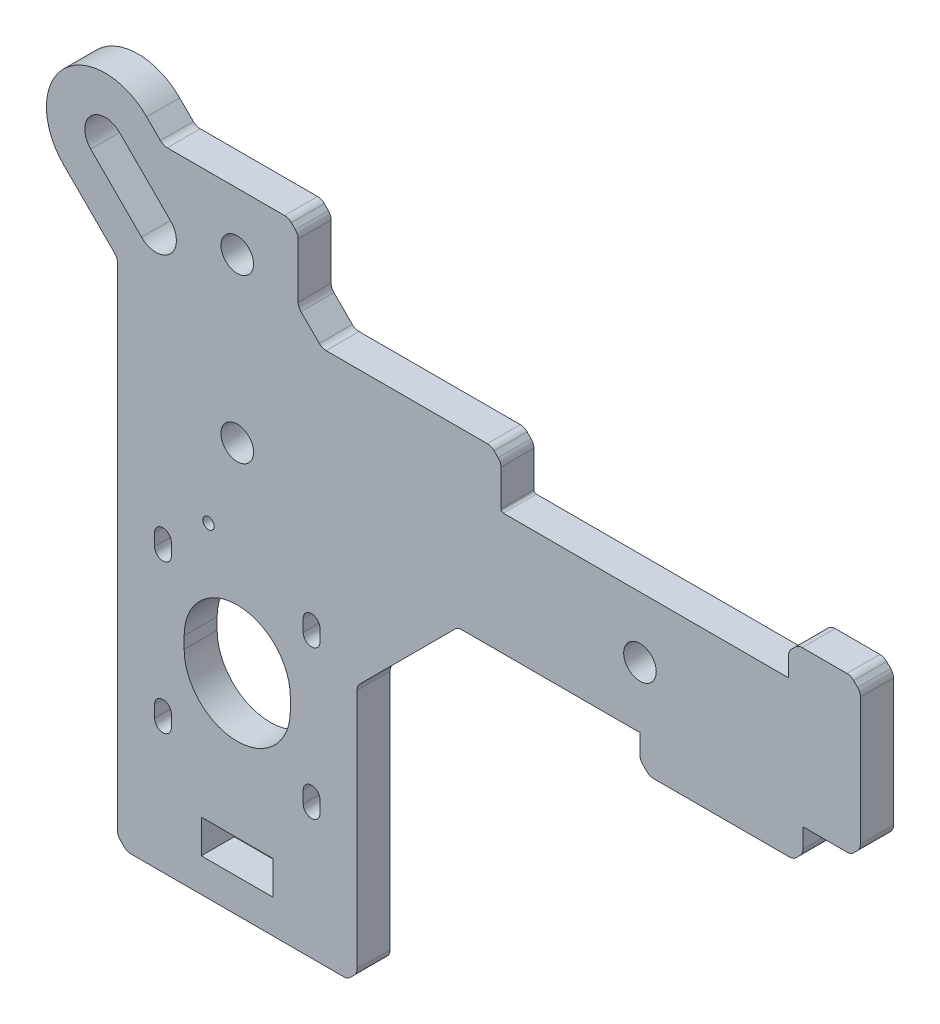
from build123d import *

# Parameters (mm, degrees)
SKETCH1_W           = 50
SKETCH1_H           = 131.35
BOSS_EXTRUDE1_DEPTH = 6.88
SKETCH2_R           = 11.075
SKETCH2_R_2         = 1.75
SKETCH2_R_3         = 3.4
CUT_EXTRUDE1_DEPTH  = 7.88
SKETCH3_W           = 15
SKETCH3_H           = 7
CUT_EXTRUDE2_DEPTH  = 6.88
SKETCH4_W           = 105
SKETCH4_H           = 25.4
BOSS_EXTRUDE2_DEPTH = 6.88
SKETCH5_R           = 3.4
CUT_EXTRUDE3_DEPTH  = 6.88
SKETCH6_W           = 34
SKETCH6_H           = 6.88
SKETCH6_W_2         = 15
BOSS_EXTRUDE3_DEPTH = 6.88
SKETCH7_W           = 12.3
SKETCH7_H           = 20.07
CUT_EXTRUDE4_DEPTH  = 6.88
SKETCH8_R           = 1.1811
CUT_EXTRUDE5_DEPTH  = 6.88
SKETCH11_W          = 30
SKETCH11_H          = 10.88
BOSS_EXTRUDE5_DEPTH = 6.88
CHAMFER2_SIZE       = 21
CUT_EXTRUDE7_DEPTH  = 10
CHAMFER5_SIZE       = 5
CHAMFER3_SIZE       = 2
SKETCH16_R          = 7.068988197
BOSS_EXTRUDE7_DEPTH = 6.88
CUT_EXTRUDE10_DEPTH = 10
BOSS_EXTRUDE8_DEPTH = 6.88
FILLET1_R           = 2
FILLET3_R           = 0.5
CUT_EXTRUDE12_DEPTH = 1


with BuildPart() as part:
    # Sketch1 → Boss-Extrude1 (new body)
    with BuildSketch(Plane.XY):
        Rectangle(SKETCH1_W, SKETCH1_H)
    extrude(amount=BOSS_EXTRUDE1_DEPTH)

    # Sketch2 → Cut-Extrude1 (cut, through all)
    with BuildSketch(Plane.XY.offset(6.88)):
        with Locations((0, -20.675)):
            Circle(SKETCH2_R)
        with Locations((-15.5, -5.175)):
            Circle(SKETCH2_R_2)
        with Locations((-15.5, -36.175)):
            Circle(SKETCH2_R_2)
        with Locations((15.5, -36.175)):
            Circle(SKETCH2_R_2)
        with Locations((15.5, -5.175)):
            Circle(SKETCH2_R_2)
        with Locations((0, 53.675)):
            Circle(SKETCH2_R_3)
        with Locations((0, 19.675)):
            Circle(SKETCH2_R_3)
    extrude(amount=-CUT_EXTRUDE1_DEPTH, mode=Mode.SUBTRACT)

    # Sketch3 → Cut-Extrude2 (cut)
    with BuildSketch(Plane.XY.offset(6.88)):
        with Locations((0, -55.175)):
            Rectangle(SKETCH3_W, SKETCH3_H)
    extrude(amount=-CUT_EXTRUDE2_DEPTH, mode=Mode.SUBTRACT)

    # Sketch4 → Boss-Extrude2 (add)
    with BuildSketch(Plane.XY.offset(6.88)):
        with Locations((77.5, 22.025)):
            Rectangle(SKETCH4_W, SKETCH4_H)
    extrude(amount=-BOSS_EXTRUDE2_DEPTH)

    # Sketch5 → Cut-Extrude3 (cut)
    with BuildSketch(Plane.XY.offset(6.88)):
        with Locations((118, 22.025)):
            Circle(SKETCH5_R)
        with Locations((84, 22.025)):
            Circle(SKETCH5_R)
    extrude(amount=-CUT_EXTRUDE3_DEPTH, mode=Mode.SUBTRACT)

    # Sketch6 → Boss-Extrude3 (add)
    with BuildSketch(Plane.XY.offset(6.88)):
        with Locations((101, 5.885)):
            Rectangle(SKETCH6_W, SKETCH6_H)
        with Locations((122.5, 38.165)):
            Rectangle(SKETCH6_W_2, SKETCH6_H)
    extrude(amount=-BOSS_EXTRUDE3_DEPTH)

    # Sketch7 → Cut-Extrude4 (cut)
    with BuildSketch(Plane.XY.offset(6.88)):
        with Locations((-18.85, 55.64)):
            Rectangle(SKETCH7_W, SKETCH7_H)
        with Locations((18.85, 55.64)):
            Rectangle(SKETCH7_W, SKETCH7_H)
    extrude(amount=-CUT_EXTRUDE4_DEPTH, mode=Mode.SUBTRACT)

    # Sketch8 → Cut-Extrude5 (cut)
    with BuildSketch(Plane.XY.offset(6.88)):
        with Locations((-6, 2.175)):
            Circle(SKETCH8_R)
    extrude(amount=-CUT_EXTRUDE5_DEPTH, mode=Mode.SUBTRACT)

    # Sketch11 → Boss-Extrude5 (add)
    with BuildSketch(Plane.XY.offset(6.88)):
        with Locations((40, 40.165)):
            Rectangle(SKETCH11_W, SKETCH11_H)
    extrude(amount=-BOSS_EXTRUDE5_DEPTH)

    # Chamfer2
    chamfer2_edges = [part.edges().sort_by_distance(p)[0] for p in [
        (25, 9.325, 3.44),
    ]]
    chamfer(chamfer2_edges, length=CHAMFER2_SIZE)

    # Sketch12 → Cut-Extrude7 (cut)
    with BuildSketch(Plane.XY.offset(6.88)):
        with BuildLine():
            Line((-13.75, -5.175), (-13.75, -7.675))
            ThreePointArc((-13.75, -7.675), (-15.5, -9.425), (-17.25, -7.675))
            Line((-17.25, -7.675), (-17.25, -5.175))
            ThreePointArc((-17.25, -5.175), (-15.5, -3.425), (-13.75, -5.175))
        make_face()
        with BuildLine():
            Line((17.25, -5.175), (17.25, -7.675))
            ThreePointArc((17.25, -7.675), (15.5, -9.425), (13.75, -7.675))
            Line((13.75, -7.675), (13.75, -5.175))
            ThreePointArc((13.75, -5.175), (15.5, -3.425), (17.25, -5.175))
        make_face()
        with BuildLine():
            Line((-13.75, -36.175), (-13.75, -38.675))
            ThreePointArc((-13.75, -38.675), (-15.5, -40.425), (-17.25, -38.675))
            Line((-17.25, -38.675), (-17.25, -36.175))
            ThreePointArc((-17.25, -36.175), (-15.5, -34.425), (-13.75, -36.175))
        make_face()
        with BuildLine():
            Line((17.25, -36.175), (17.25, -38.675))
            ThreePointArc((17.25, -38.675), (15.5, -40.425), (13.75, -38.675))
            Line((13.75, -38.675), (13.75, -36.175))
            ThreePointArc((13.75, -36.175), (15.5, -34.425), (17.25, -36.175))
        make_face()
        with BuildLine():
            Line((11.075, -20.675), (11.075, -23.175))
            ThreePointArc((11.075, -23.175), (0, -34.25), (-11.075, -23.175))
            Line((-11.075, -23.175), (-11.075, -20.675))
            ThreePointArc((-11.075, -20.675), (0, -9.6), (11.075, -20.675))
        make_face()
    extrude(amount=-CUT_EXTRUDE7_DEPTH, mode=Mode.SUBTRACT)

    # Chamfer5
    chamfer5_edges = [part.edges().sort_by_distance(p)[0] for p in [
        (-12.7, 45.605, 3.44),
        (12.7, 45.605, 3.44),
    ]]
    chamfer(chamfer5_edges, length=CHAMFER5_SIZE)

    # Chamfer3
    chamfer3_edges = [part.edges().sort_by_distance(p)[0] for p in [
        (115, 41.605, 3.44),
        (-25, 45.605, 3.44),
        (-12.7, 65.675, 3.44),
        (12.7, 65.675, 3.44),
        (55, 45.605, 3.44),
        (130, 9.325, 3.44),
        (25, -65.675, 3.44),
        (-25, -65.675, 3.44),
        (84, 2.445, 3.44),
        (118, 2.445, 3.44),
        (130, 41.605, 3.44),
    ]]
    chamfer(chamfer3_edges, length=CHAMFER3_SIZE)

    # Sketch16 → Boss-Extrude7 (add)
    with BuildSketch(Plane.XY.offset(6.88)):
        with Locations((118, 22.025)):
            Circle(SKETCH16_R)
    extrude(amount=-BOSS_EXTRUDE7_DEPTH)

    # Sketch17 → Cut-Extrude10 (cut)
    with BuildSketch(Plane.XY):
        with BuildLine():
            Line((-30.561805538, 57.456397898), (-19.95520382, 46.84979618))
            ThreePointArc((-19.95520382, 46.84979618), (-13.94479618, 46.84979618), (-13.94479618, 52.86020382))
            Line((-13.94479618, 52.86020382), (-24.551397898, 63.466805538))
            ThreePointArc((-24.551397898, 63.466805538), (-30.561805538, 63.466805538), (-30.561805538, 57.456397898))
        make_face()
    extrude(amount=CUT_EXTRUDE10_DEPTH, mode=Mode.SUBTRACT)

    # Sketch18 → Boss-Extrude8 (add)
    with BuildSketch(Plane(origin=(0, 0, 0), x_dir=(-1, 0, 0), z_dir=(0, 0, -1))):
        with BuildLine():
            Line((10.7, 65.675), (15.445883861, 65.675))
            Line((15.445883861, 65.675), (18.894543648, 69.123659787))
            ThreePointArc((18.894543648, 69.123659787), (36.218659787, 69.123659787), (36.218659787, 51.799543648))
            Line((36.218659787, 51.799543648), (25.61205807, 41.19294193))
            ThreePointArc((25.61205807, 41.19294193), (8.28794193, 41.19294193), (8.28794193, 58.51705807))
            Line((8.28794193, 58.51705807), (10.7, 60.929116139))
            Line((10.7, 60.929116139), (10.7, 65.675))
        make_face()
        with BuildLine():
            Line((24.551397898, 63.466805538), (13.94479618, 52.86020382))
            ThreePointArc((13.94479618, 52.86020382), (13.94479618, 46.84979618), (19.95520382, 46.84979618))
            Line((19.95520382, 46.84979618), (30.561805538, 57.456397898))
            ThreePointArc((30.561805538, 57.456397898), (30.561805538, 63.466805538), (24.551397898, 63.466805538))
        make_face(mode=Mode.SUBTRACT)
    extrude(amount=-BOSS_EXTRUDE8_DEPTH)

    # Fillet1
    fillet1_edges = [part.edges().sort_by_distance(p)[0] for p in [
        (25, -11.675, 3.44),
        (46, 9.325, 3.44),
        (17.7, 45.605, 3.44),
        (12.7, 50.605, 3.44),
        (55, 43.605, 3.44),
        (53, 45.605, 3.44),
        (25, -63.675, 3.44),
        (-23, -65.675, 3.44),
        (23, -65.675, 3.44),
        (-25, -63.675, 3.44),
        (84, 4.445, 3.44),
        (116, 2.445, 3.44),
        (86, 2.445, 3.44),
        (118, 4.445, 3.44),
        (128, 9.325, 3.44),
        (130, 39.605, 3.44),
        (130, 11.325, 3.44),
        (128, 41.605, 3.44),
        (117, 41.605, 3.44),
        (115, 39.605, 3.44),
        (10.7, 65.675, 3.44),
        (12.7, 63.675, 3.44),
        (-25, 40.621365829, 3.44),
        (-15.445883861, 65.675, 3.44),
    ]]
    fillet(fillet1_edges, radius=FILLET1_R)

    # Fillet3
    fillet3_edges = [part.edges().sort_by_distance(p)[0] for p in [
        (55, 34.725, 3.44),
    ]]
    fillet(fillet3_edges, radius=FILLET3_R)

    # Sketch20 → Cut-Extrude12 (cut)
    with BuildSketch(Plane(origin=(0, 0, 0), x_dir=(-1, 0, 0), z_dir=(0, 0, -1))):
        with BuildLine():
            add(Edge.make_bspline(
                [(-92.176118827, 25.905208333), (-92.207609253, 25.885249103), (-92.27413067, 25.843086565), (-92.379644578, 25.77698727), (-92.494037103, 25.701465551), (-92.57352195, 25.648367083), (-92.614969136, 25.620679012)],
                knots=[0, 0, 0, 0, 0.000111849, 0.000236274, 0.000373509, 0.000523045, 0.000523045, 0.000523045, 0.000523045], degree=3))
            add(Edge.make_bspline(
                [(-92.614969136, 25.620679012), (-92.662404679, 25.584307245), (-92.761727857, 25.508150015), (-92.907142323, 25.376423018), (-93.060930204, 25.22913639), (-93.220108029, 25.062389169), (-93.385646896, 24.877064144), (-93.557813869, 24.673637627), (-93.73696677, 24.452576052), (-93.855122845, 24.296756439), (-93.916087963, 24.216358025)],
                knots=[0, 0, 0, 0, 0.000179255, 0.000375335, 0.000588161, 0.000818048, 0.001066673, 0.001333551, 0.001617493, 0.001920172, 0.001920172, 0.001920172, 0.001920172], degree=3))
            add(Edge.make_bspline(
                [(-93.916087963, 24.216358025), (-94.108063083, 23.956934248), (-94.492167102, 23.437878884), (-94.875810058, 22.918482647), (-95.067708333, 22.658680556)],
                knots=[0, 0, 0, 0, 0.000968192, 0.00193716, 0.00193716, 0.00193716, 0.00193716], degree=3))
            Line((-95.067708333, 22.658680556), (-95.080246914, 22.642283951))
            add(Edge.make_bspline(
                [(-95.080246914, 22.642283951), (-95.056778658, 22.642981354), (-95.002774214, 22.644586199), (-94.911432114, 22.645838397), (-94.798951632, 22.650626132), (-94.665499511, 22.65385177), (-94.51086182, 22.658852663), (-94.335662809, 22.664931996), (-94.139184926, 22.670111901), (-94.001281489, 22.675258941), (-93.928626543, 22.677970679)],
                knots=[0, 0, 0, 0, 7.0435e-05, 0.000162084, 0.000274033, 0.000408155, 0.000562551, 0.000738187, 0.000934067, 0.001152182, 0.001152182, 0.001152182, 0.001152182], degree=3))
            add(Edge.make_bspline(
                [(-93.928626543, 22.677970679), (-93.870432307, 22.679823945), (-93.756934213, 22.683438429), (-93.59140274, 22.689972177), (-93.435112374, 22.693093755), (-93.288205427, 22.697367438), (-93.150278147, 22.700333137), (-93.021344435, 22.701795401), (-92.901436744, 22.704503212), (-92.824589806, 22.7041718), (-92.787615741, 22.704012346)],
                knots=[0, 0, 0, 0, 0.000174672, 0.000340667, 0.000496965, 0.000643621, 0.000781576, 0.000910834, 0.001030448, 0.001141366, 0.001141366, 0.001141366, 0.001141366], degree=3))
            add(Edge.make_bspline(
                [(-92.787615741, 22.704012346), (-92.750322248, 22.703645813), (-92.678628498, 22.702941182), (-92.575724057, 22.702646446), (-92.4821602, 22.699504221), (-92.398251171, 22.695626693), (-92.323550138, 22.691431602), (-92.258413041, 22.683947443), (-92.202177723, 22.678336508), (-92.168365895, 22.671457686), (-92.152970679, 22.668325617)],
                knots=[0, 0, 0, 0, 0.000111887, 0.000215094, 0.000308695, 0.000392696, 0.000467119, 0.000533052, 0.0005894, 0.000636503, 0.000636503, 0.000636503, 0.000636503], degree=3))
            add(Edge.make_bspline(
                [(-92.152970679, 22.668325617), (-92.121922389, 22.660611117), (-92.063104717, 22.64599682), (-91.981833185, 22.615176402), (-91.912840879, 22.577371011), (-91.854089468, 22.534215085), (-91.8092771, 22.481948695), (-91.775555444, 22.423880962), (-91.75381085, 22.359166515), (-91.749246052, 22.313548569), (-91.74691358, 22.290239198)],
                knots=[0, 0, 0, 0, 9.5928e-05, 0.000181726, 0.000259857, 0.000331426, 0.000399113, 0.000464792, 0.000531893, 0.000602004, 0.000602004, 0.000602004, 0.000602004], degree=3))
            add(Edge.make_bspline(
                [(-91.74691358, 22.290239198), (-91.74708372, 22.255604392), (-91.747409573, 22.189271373), (-91.776332269, 22.095574102), (-91.823866055, 22.011681935), (-91.871846683, 21.969457683), (-91.896412037, 21.947839506)],
                knots=[0, 0, 0, 0, 0.000103364, 0.000197965, 0.000290928, 0.000388458, 0.000388458, 0.000388458, 0.000388458], degree=3))
            add(Edge.make_bspline(
                [(-91.896412037, 21.947839506), (-91.919657886, 21.931154191), (-91.96601492, 21.89788022), (-92.046189812, 21.864273965), (-92.132923824, 21.843392184), (-92.193354401, 21.841027474), (-92.224344136, 21.839814815)],
                knots=[0, 0, 0, 0, 8.5602e-05, 0.000170709, 0.000258907, 0.000351745, 0.000351745, 0.000351745, 0.000351745], degree=3))
            add(Edge.make_bspline(
                [(-92.224344136, 21.839814815), (-92.242027117, 21.840107332), (-92.281257219, 21.840756287), (-92.345905884, 21.842531254), (-92.422393495, 21.846831609), (-92.506624979, 21.851351677), (-92.590850279, 21.855985091), (-92.667018739, 21.860242143), (-92.731667119, 21.862022298), (-92.770897252, 21.862670697), (-92.788580247, 21.862962963)],
                knots=[0, 0, 0, 0, 5.3057e-05, 0.000117707, 0.000194001, 0.000282866, 0.000370769, 0.000447062, 0.000511713, 0.00056477, 0.00056477, 0.00056477, 0.00056477], degree=3))
            add(Edge.make_bspline(
                [(-92.788580247, 21.862962963), (-92.832304768, 21.8630363), (-92.924898931, 21.863191604), (-93.071501544, 21.861875308), (-93.23353849, 21.860957704), (-93.411012345, 21.860277073), (-93.604229626, 21.857986087), (-93.812884881, 21.856117963), (-94.036977764, 21.854445839), (-94.271026235, 21.851388889), (-94.505074706, 21.848331938), (-94.729167588, 21.846659815), (-94.937822843, 21.84479169), (-95.131040124, 21.842500705), (-95.308513979, 21.841820074), (-95.470550925, 21.84090247), (-95.617153539, 21.839586174), (-95.709747701, 21.839741478), (-95.753472222, 21.839814815)],
                knots=[0, 0, 0, 0, 0.000131173, 0.000277781, 0.000439821, 0.000617293, 0.000810203, 0.00101951, 0.001243284, 0.001482499, 0.001721714, 0.001945488, 0.002154795, 0.002347705, 0.002525177, 0.002687217, 0.002833825, 0.002964998, 0.002964998, 0.002964998, 0.002964998], degree=3))
            add(Edge.make_bspline(
                [(-95.753472222, 21.839814815), (-95.787028661, 21.841001406), (-95.851906723, 21.843295563), (-95.944414623, 21.864009229), (-96.02866586, 21.897346885), (-96.07681669, 21.931101007), (-96.100694444, 21.947839506)],
                knots=[0, 0, 0, 0, 0.000100536, 0.000194376, 0.000283037, 0.000370254, 0.000370254, 0.000370254, 0.000370254], degree=3))
            add(Edge.make_bspline(
                [(-96.100694444, 21.947839506), (-96.124158174, 21.968265066), (-96.170509078, 22.008614286), (-96.217849179, 22.089217566), (-96.248316163, 22.180043643), (-96.251456225, 22.244962061), (-96.25308642, 22.278665123)],
                knots=[0, 0, 0, 0, 9.2763e-05, 0.000183247, 0.00027658, 0.000377351, 0.000377351, 0.000377351, 0.000377351], degree=3))
            add(Edge.make_bspline(
                [(-96.25308642, 22.278665123), (-96.250403037, 22.320065133), (-96.244708631, 22.407920069), (-96.20320208, 22.543312317), (-96.140370069, 22.689617936), (-96.082939963, 22.786614832), (-96.052469136, 22.838078704)],
                knots=[0, 0, 0, 0, 0.000124092, 0.000263335, 0.000421896, 0.00060111, 0.00060111, 0.00060111, 0.00060111], degree=3))
            add(Edge.make_bspline(
                [(-96.052469136, 22.838078704), (-96.046125899, 22.848103648), (-96.031387385, 22.87139661), (-96.003747894, 22.90965583), (-95.970219564, 22.958262773), (-95.928838211, 23.015891162), (-95.879586871, 23.082162594), (-95.823356321, 23.157500794), (-95.761050219, 23.242583185), (-95.716264948, 23.301749479), (-95.692708333, 23.33287037)],
                knots=[0, 0, 0, 0, 3.5582e-05, 8.2675e-05, 0.000141542, 0.000212739, 0.000295496, 0.000389247, 0.000494767, 0.000611858, 0.000611858, 0.000611858, 0.000611858], degree=3))
            add(Edge.make_bspline(
                [(-95.692708333, 23.33287037), (-95.518223346, 23.571491327), (-95.169294242, 24.048677346), (-94.819277831, 24.525066398), (-94.644290123, 24.763233025)],
                knots=[0, 0, 0, 0, 0.000886828, 0.001773449, 0.001773449, 0.001773449, 0.001773449], degree=3))
            add(Edge.make_bspline(
                [(-94.644290123, 24.763233025), (-94.593156431, 24.830665338), (-94.492812061, 24.962993997), (-94.339636161, 25.154045082), (-94.189913778, 25.33608467), (-94.042062499, 25.507908914), (-93.897381738, 25.669989178), (-93.755944923, 25.822769172), (-93.61567165, 25.96490498), (-93.521495789, 26.054925066), (-93.475308642, 26.099074074)],
                knots=[0, 0, 0, 0, 0.00025387, 0.000498193, 0.00073456, 0.000960948, 0.001178174, 0.001386322, 0.001585473, 0.001777148, 0.001777148, 0.001777148, 0.001777148], degree=3))
            add(Edge.make_bspline(
                [(-93.475308642, 26.099074074), (-93.515487882, 26.095125803), (-93.593558079, 26.087454122), (-93.707057235, 26.077798917), (-93.81319485, 26.070278235), (-93.91157534, 26.063541847), (-94.002525722, 26.057433594), (-94.086132472, 26.053525752), (-94.162672602, 26.051711725), (-94.211226287, 26.051127367), (-94.234375, 26.050848765)],
                knots=[0, 0, 0, 0, 0.000121118, 0.000235337, 0.000341713, 0.000440324, 0.000531172, 0.000615173, 0.000691393, 0.000760844, 0.000760844, 0.000760844, 0.000760844], degree=3))
            Line((-94.234375, 26.050848765), (-95.521990741, 26.050848765))
            add(Edge.make_bspline(
                [(-95.521990741, 26.050848765), (-95.536143187, 26.050307021), (-95.570281823, 26.049000221), (-95.623911533, 26.044154758), (-95.677528663, 26.039156036), (-95.711348491, 26.037879774), (-95.725501543, 26.037345679)],
                knots=[0, 0, 0, 0, 4.2482e-05, 0.000102476, 0.000161508, 0.00020399, 0.00020399, 0.00020399, 0.00020399], degree=3))
            add(Edge.make_bspline(
                [(-95.725501543, 26.037345679), (-95.755852152, 26.03888665), (-95.814761269, 26.041877602), (-95.899710439, 26.063532065), (-95.977316675, 26.100544591), (-96.022176817, 26.135496538), (-96.044753086, 26.15308642)],
                knots=[0, 0, 0, 0, 9.0991e-05, 0.00017661, 0.000261163, 0.000346825, 0.000346825, 0.000346825, 0.000346825], degree=3))
            add(Edge.make_bspline(
                [(-96.044753086, 26.15308642), (-96.067115132, 26.17531067), (-96.111627257, 26.219548509), (-96.158308766, 26.302898043), (-96.18601376, 26.397292472), (-96.189528796, 26.463779641), (-96.191358025, 26.49837963)],
                knots=[0, 0, 0, 0, 9.4206e-05, 0.000187519, 0.000283044, 0.000386696, 0.000386696, 0.000386696, 0.000386696], degree=3))
            add(Edge.make_bspline(
                [(-96.191358025, 26.49837963), (-96.189491329, 26.534956575), (-96.185929622, 26.604746416), (-96.154220664, 26.70233535), (-96.101639887, 26.785152004), (-96.027602285, 26.852859523), (-95.931812876, 26.902326904), (-95.817496617, 26.938906064), (-95.6824656, 26.959024529), (-95.586033757, 26.961792973), (-95.534529321, 26.963271605)],
                knots=[0, 0, 0, 0, 0.000109504, 0.000208937, 0.00030392, 0.000400852, 0.000506156, 0.000624806, 0.000759588, 0.000914102, 0.000914102, 0.000914102, 0.000914102], degree=3))
            add(Edge.make_bspline(
                [(-95.534529321, 26.963271605), (-95.492729315, 26.962825252), (-95.400095623, 26.961836081), (-95.247370632, 26.955423533), (-95.067314931, 26.945834529), (-94.868701514, 26.932361311), (-94.670079178, 26.919028557), (-94.489385053, 26.909354482), (-94.336336268, 26.902995078), (-94.243381644, 26.901993569), (-94.20158179, 26.90154321)],
                knots=[0, 0, 0, 0, 0.000125401, 0.000277902, 0.000458523, 0.000666331, 0.000875101, 0.001055722, 0.001209187, 0.001334588, 0.001334588, 0.001334588, 0.001334588], degree=3))
            add(Edge.make_bspline(
                [(-94.20158179, 26.90154321), (-94.154963992, 26.90154321), (-94.051440329, 26.90154321), (-93.880722737, 26.90154321), (-93.679140947, 26.90154321), (-93.456661523, 26.90154321), (-93.234182099, 26.90154321), (-93.031957305, 26.90154321), (-92.86091821, 26.90154321), (-92.757073045, 26.90154321), (-92.710455247, 26.90154321)],
                knots=[0, 0, 0, 0, 0.000139853, 0.000310571, 0.000512153, 0.000744599, 0.000978009, 0.001179591, 0.001351273, 0.001491127, 0.001491127, 0.001491127, 0.001491127], degree=3))
            add(Edge.make_bspline(
                [(-92.710455247, 26.90154321), (-92.671547359, 26.901135917), (-92.59627342, 26.90034794), (-92.486922851, 26.895353706), (-92.385185927, 26.888187331), (-92.290856723, 26.876612531), (-92.204294931, 26.861233898), (-92.125077335, 26.842989014), (-92.053219755, 26.822295655), (-91.989271759, 26.796795933), (-91.93196799, 26.769348572), (-91.882478339, 26.737809961), (-91.841457161, 26.701977432), (-91.805795962, 26.665006673), (-91.779332502, 26.622489666), (-91.761290181, 26.576627642), (-91.748951429, 26.527952713), (-91.747600318, 26.494277037), (-91.74691358, 26.477160494)],
                knots=[0, 0, 0, 0, 0.000116721, 0.000225817, 0.000328345, 0.000422616, 0.000510782, 0.000591967, 0.000666428, 0.000734847, 0.000798255, 0.000856845, 0.000910198, 0.00096139, 0.001010362, 0.001059258, 0.001108852, 0.001160117, 0.001160117, 0.001160117, 0.001160117], degree=3))
            add(Edge.make_bspline(
                [(-91.74691358, 26.477160494), (-91.748241521, 26.454185835), (-91.75094759, 26.407368242), (-91.773053698, 26.337351197), (-91.807406524, 26.267000279), (-91.853928871, 26.194731303), (-91.916345071, 26.123989311), (-91.989339803, 26.049898012), (-92.078125971, 25.977369741), (-92.142467631, 25.929988891), (-92.176118827, 25.905208333)],
                knots=[0, 0, 0, 0, 6.8812e-05, 0.000140225, 0.000218308, 0.000303381, 0.000397117, 0.000500783, 0.000615137, 0.000740522, 0.000740522, 0.000740522, 0.000740522], degree=3))
        make_face()
    extrude(amount=-CUT_EXTRUDE12_DEPTH, mode=Mode.SUBTRACT)


solid = part.part
